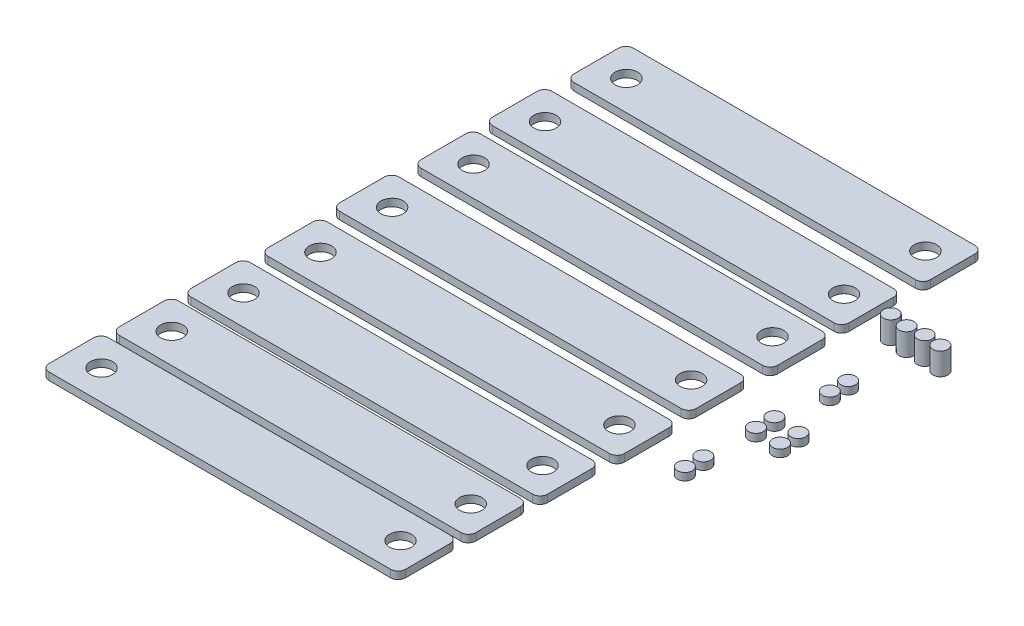
from build123d import *

# Parameters (mm, degrees)
SKETCH3_R              = 5
BOSS_EXTRUDE2_DEPTH    = 5
BOSS_EXTRUDE2_2_DEPTH  = 5
BOSS_EXTRUDE2_3_DEPTH  = 5
BOSS_EXTRUDE2_4_DEPTH  = 5
BOSS_EXTRUDE2_5_DEPTH  = 5
BOSS_EXTRUDE2_6_DEPTH  = 5
BOSS_EXTRUDE2_7_DEPTH  = 5
BOSS_EXTRUDE2_8_DEPTH  = 5
SKETCH3_R_2            = 7.5
BOSS_EXTRUDE2_9_DEPTH  = 5
BOSS_EXTRUDE2_10_DEPTH = 5
BOSS_EXTRUDE2_11_DEPTH = 5
BOSS_EXTRUDE2_12_DEPTH = 5
BOSS_EXTRUDE2_13_DEPTH = 5
BOSS_EXTRUDE2_14_DEPTH = 5
BOSS_EXTRUDE2_15_DEPTH = 5
BOSS_EXTRUDE2_16_DEPTH = 5
SKETCH9_R              = 5
BOSS_EXTRUDE3_DEPTH    = 15
BOSS_EXTRUDE3_2_DEPTH  = 15
BOSS_EXTRUDE3_3_DEPTH  = 15
BOSS_EXTRUDE3_4_DEPTH  = 15


with BuildPart() as part:
    # Sketch3 → Boss-Extrude2 (new body)
    with BuildSketch(Plane(origin=(0, 0, 0), x_dir=(1, 0, 0), z_dir=(0, 1, 0))):
        with Locations((149.537044307, 9.749777699)):
            Circle(SKETCH3_R)
    extrude(amount=BOSS_EXTRUDE2_DEPTH)


with BuildPart() as body_2:
    # Sketch3 → Boss-Extrude2 2 (new body)
    with BuildSketch(Plane(origin=(0, 0, 0), x_dir=(1, 0, 0), z_dir=(0, 1, 0))):
        with Locations((149.537044307, -2.604675007)):
            Circle(SKETCH3_R)
    extrude(amount=BOSS_EXTRUDE2_2_DEPTH)


with BuildPart() as body_3:
    # Sketch3 → Boss-Extrude2 3 (new body)
    with BuildSketch(Plane(origin=(0, 0, 0), x_dir=(1, 0, 0), z_dir=(0, 1, 0))):
        with Locations((145.856610502, -36.255644862)):
            Circle(SKETCH3_R)
    extrude(amount=BOSS_EXTRUDE2_3_DEPTH)


with BuildPart() as body_4:
    # Sketch3 → Boss-Extrude2 4 (new body)
    with BuildSketch(Plane(origin=(0, 0, 0), x_dir=(1, 0, 0), z_dir=(0, 1, 0))):
        with Locations((145.856610502, -48.610097567)):
            Circle(SKETCH3_R)
    extrude(amount=BOSS_EXTRUDE2_4_DEPTH)


with BuildPart() as body_5:
    # Sketch3 → Boss-Extrude2 5 (new body)
    with BuildSketch(Plane(origin=(0, 0, 0), x_dir=(1, 0, 0), z_dir=(0, 1, 0))):
        with Locations((144.75248036, -82.997154184)):
            Circle(SKETCH3_R)
    extrude(amount=BOSS_EXTRUDE2_5_DEPTH)


with BuildPart() as body_6:
    # Sketch3 → Boss-Extrude2 6 (new body)
    with BuildSketch(Plane(origin=(0, 0, 0), x_dir=(1, 0, 0), z_dir=(0, 1, 0))):
        with Locations((144.75248036, -95.351606889)):
            Circle(SKETCH3_R)
    extrude(amount=BOSS_EXTRUDE2_6_DEPTH)


with BuildPart() as body_7:
    # Sketch3 → Boss-Extrude2 7 (new body)
    with BuildSketch(Plane(origin=(0, 0, 0), x_dir=(1, 0, 0), z_dir=(0, 1, 0))):
        with Locations((163.154649385, -37.359775004)):
            Circle(SKETCH3_R)
    extrude(amount=BOSS_EXTRUDE2_7_DEPTH)


with BuildPart() as body_8:
    # Sketch3 → Boss-Extrude2 8 (new body)
    with BuildSketch(Plane(origin=(0, 0, 0), x_dir=(1, 0, 0), z_dir=(0, 1, 0))):
        with Locations((163.154649385, -49.714227709)):
            Circle(SKETCH3_R)
    extrude(amount=BOSS_EXTRUDE2_8_DEPTH)


with BuildPart() as body_9:
    # Sketch3 → Boss-Extrude2 9 (new body)
    with BuildSketch(Plane(origin=(0, 0, 0), x_dir=(1, 0, 0), z_dir=(0, 1, 0))):
        with BuildLine():
            Line((-120.270545649, -22.829813293), (109.729454351, -22.829813293))
            ThreePointArc((109.729454351, -22.829813293), (113.264988257, -24.294279387), (114.729454351, -27.829813293))
            Line((114.729454351, -27.829813293), (114.729454351, -57.829813293))
            ThreePointArc((114.729454351, -57.829813293), (113.264988257, -61.365347199), (109.729454351, -62.829813293))
            Line((109.729454351, -62.829813293), (-120.270545649, -62.829813293))
            ThreePointArc((-120.270545649, -62.829813293), (-123.806079555, -61.365347199), (-125.270545649, -57.829813293))
            Line((-125.270545649, -57.829813293), (-125.270545649, -27.829813293))
            ThreePointArc((-125.270545649, -27.829813293), (-123.806079555, -24.294279387), (-120.270545649, -22.829813293))
        make_face()
        with Locations((-104.955380734, -42.829813293)):
            Circle(SKETCH3_R_2, mode=Mode.SUBTRACT)
        with Locations((96.367895313, -42.829813293)):
            Circle(SKETCH3_R_2, mode=Mode.SUBTRACT)
    extrude(amount=BOSS_EXTRUDE2_9_DEPTH)


with BuildPart() as body_10:
    # Sketch3 → Boss-Extrude2 10 (new body)
    with BuildSketch(Plane(origin=(0, 0, 0), x_dir=(1, 0, 0), z_dir=(0, 1, 0))):
        with BuildLine():
            Line((-118.048872791, 29.749777699), (111.951127209, 29.749777699))
            ThreePointArc((111.951127209, 29.749777699), (115.486661115, 28.285311605), (116.951127209, 24.749777699))
            Line((116.951127209, 24.749777699), (116.951127209, -5.250222301))
            ThreePointArc((116.951127209, -5.250222301), (115.486661115, -8.785756207), (111.951127209, -10.250222301))
            Line((111.951127209, -10.250222301), (-118.048872791, -10.250222301))
            ThreePointArc((-118.048872791, -10.250222301), (-121.584406697, -8.785756207), (-123.048872791, -5.250222301))
            Line((-123.048872791, -5.250222301), (-123.048872791, 24.749777699))
            ThreePointArc((-123.048872791, 24.749777699), (-121.584406697, 28.285311605), (-118.048872791, 29.749777699))
        make_face()
        with Locations((-102.733707875, 9.749777699)):
            Circle(SKETCH3_R_2, mode=Mode.SUBTRACT)
        with Locations((98.589568172, 9.749777699)):
            Circle(SKETCH3_R_2, mode=Mode.SUBTRACT)
    extrude(amount=BOSS_EXTRUDE2_10_DEPTH)


with BuildPart() as body_11:
    # Sketch3 → Boss-Extrude2 11 (new body)
    with BuildSketch(Plane(origin=(0, 0, 0), x_dir=(1, 0, 0), z_dir=(0, 1, 0))):
        with BuildLine():
            Line((-120.365844272, -122.797427213), (109.634155728, -122.797427213))
            ThreePointArc((109.634155728, -122.797427213), (113.169689634, -124.261893307), (114.634155728, -127.797427213))
            Line((114.634155728, -127.797427213), (114.634155728, -157.797427213))
            ThreePointArc((114.634155728, -157.797427213), (113.169689634, -161.332961119), (109.634155728, -162.797427213))
            Line((109.634155728, -162.797427213), (-120.365844272, -162.797427213))
            ThreePointArc((-120.365844272, -162.797427213), (-123.901378178, -161.332961119), (-125.365844272, -157.797427213))
            Line((-125.365844272, -157.797427213), (-125.365844272, -127.797427213))
            ThreePointArc((-125.365844272, -127.797427213), (-123.901378178, -124.261893307), (-120.365844272, -122.797427213))
        make_face()
        with Locations((-105.050679357, -142.797427213)):
            Circle(SKETCH3_R_2, mode=Mode.SUBTRACT)
        with Locations((96.27259669, -142.797427213)):
            Circle(SKETCH3_R_2, mode=Mode.SUBTRACT)
    extrude(amount=BOSS_EXTRUDE2_11_DEPTH)


with BuildPart() as body_12:
    # Sketch3 → Boss-Extrude2 12 (new body)
    with BuildSketch(Plane(origin=(0, 0, 0), x_dir=(1, 0, 0), z_dir=(0, 1, 0))):
        with BuildLine():
            Line((-118.17072499, -73.187731426), (111.82927501, -73.187731426))
            ThreePointArc((111.82927501, -73.187731426), (115.364808916, -74.65219752), (116.82927501, -78.187731426))
            Line((116.82927501, -78.187731426), (116.82927501, -108.187731426))
            ThreePointArc((116.82927501, -108.187731426), (115.364808916, -111.723265332), (111.82927501, -113.187731426))
            Line((111.82927501, -113.187731426), (-118.17072499, -113.187731426))
            ThreePointArc((-118.17072499, -113.187731426), (-121.706258896, -111.723265332), (-123.17072499, -108.187731426))
            Line((-123.17072499, -108.187731426), (-123.17072499, -78.187731426))
            ThreePointArc((-123.17072499, -78.187731426), (-121.706258896, -74.65219752), (-118.17072499, -73.187731426))
        make_face()
        with Locations((-102.855560074, -93.187731426)):
            Circle(SKETCH3_R_2, mode=Mode.SUBTRACT)
        with Locations((98.467715973, -93.187731426)):
            Circle(SKETCH3_R_2, mode=Mode.SUBTRACT)
    extrude(amount=BOSS_EXTRUDE2_12_DEPTH)


with BuildPart() as body_13:
    # Sketch3 → Boss-Extrude2 13 (new body)
    with BuildSketch(Plane(origin=(0, 0, 0), x_dir=(1, 0, 0), z_dir=(0, 1, 0))):
        with BuildLine():
            Line((-122.121939698, -169.333956004), (107.878060302, -169.333956004))
            ThreePointArc((107.878060302, -169.333956004), (111.413594208, -170.798422098), (112.878060302, -174.333956004))
            Line((112.878060302, -174.333956004), (112.878060302, -204.333956004))
            ThreePointArc((112.878060302, -204.333956004), (111.413594208, -207.86948991), (107.878060302, -209.333956004))
            Line((107.878060302, -209.333956004), (-122.121939698, -209.333956004))
            ThreePointArc((-122.121939698, -209.333956004), (-125.657473604, -207.86948991), (-127.121939698, -204.333956004))
            Line((-127.121939698, -204.333956004), (-127.121939698, -174.333956004))
            ThreePointArc((-127.121939698, -174.333956004), (-125.657473604, -170.798422098), (-122.121939698, -169.333956004))
        make_face()
        with Locations((-106.806774783, -189.333956004)):
            Circle(SKETCH3_R_2, mode=Mode.SUBTRACT)
        with Locations((94.516501264, -189.333956004)):
            Circle(SKETCH3_R_2, mode=Mode.SUBTRACT)
    extrude(amount=BOSS_EXTRUDE2_13_DEPTH)


with BuildPart() as body_14:
    # Sketch3 → Boss-Extrude2 14 (new body)
    with BuildSketch(Plane(origin=(0, 0, 0), x_dir=(1, 0, 0), z_dir=(0, 1, 0))):
        with BuildLine():
            Line((-118.756382516, 78.619116624), (111.243617484, 78.619116624))
            ThreePointArc((111.243617484, 78.619116624), (114.77915139, 77.15465053), (116.243617484, 73.619116624))
            Line((116.243617484, 73.619116624), (116.243617484, 43.619116624))
            ThreePointArc((116.243617484, 43.619116624), (114.77915139, 40.083582718), (111.243617484, 38.619116624))
            Line((111.243617484, 38.619116624), (-118.756382516, 38.619116624))
            ThreePointArc((-118.756382516, 38.619116624), (-122.291916422, 40.083582718), (-123.756382516, 43.619116624))
            Line((-123.756382516, 43.619116624), (-123.756382516, 73.619116624))
            ThreePointArc((-123.756382516, 73.619116624), (-122.291916422, 77.15465053), (-118.756382516, 78.619116624))
        make_face()
        with Locations((-103.441217601, 58.619116624)):
            Circle(SKETCH3_R_2, mode=Mode.SUBTRACT)
        with Locations((97.882058446, 58.619116624)):
            Circle(SKETCH3_R_2, mode=Mode.SUBTRACT)
    extrude(amount=BOSS_EXTRUDE2_14_DEPTH)


with BuildPart() as body_15:
    # Sketch3 → Boss-Extrude2 15 (new body)
    with BuildSketch(Plane(origin=(0, 0, 0), x_dir=(1, 0, 0), z_dir=(0, 1, 0))):
        with BuildLine():
            Line((-116.534709657, 131.198707616), (113.465290343, 131.198707616))
            ThreePointArc((113.465290343, 131.198707616), (117.000824248, 129.734241522), (118.465290343, 126.198707616))
            Line((118.465290343, 126.198707616), (118.465290343, 96.198707616))
            ThreePointArc((118.465290343, 96.198707616), (117.000824248, 92.66317371), (113.465290343, 91.198707616))
            Line((113.465290343, 91.198707616), (-116.534709657, 91.198707616))
            ThreePointArc((-116.534709657, 91.198707616), (-120.070243563, 92.66317371), (-121.534709657, 96.198707616))
            Line((-121.534709657, 96.198707616), (-121.534709657, 126.198707616))
            ThreePointArc((-121.534709657, 126.198707616), (-120.070243563, 129.734241522), (-116.534709657, 131.198707616))
        make_face()
        with Locations((-101.219544742, 111.198707616)):
            Circle(SKETCH3_R_2, mode=Mode.SUBTRACT)
        with Locations((100.103731305, 111.198707616)):
            Circle(SKETCH3_R_2, mode=Mode.SUBTRACT)
    extrude(amount=BOSS_EXTRUDE2_15_DEPTH)


with BuildPart() as body_16:
    # Sketch3 → Boss-Extrude2 16 (new body)
    with BuildSketch(Plane(origin=(0, 0, 0), x_dir=(1, 0, 0), z_dir=(0, 1, 0))):
        with BuildLine():
            Line((-124.37505078, -214.396177643), (105.62494922, -214.396177643))
            ThreePointArc((105.62494922, -214.396177643), (109.160483126, -215.860643737), (110.62494922, -219.396177643))
            Line((110.62494922, -219.396177643), (110.62494922, -249.396177643))
            ThreePointArc((110.62494922, -249.396177643), (109.160483126, -252.931711549), (105.62494922, -254.396177643))
            Line((105.62494922, -254.396177643), (-124.37505078, -254.396177643))
            ThreePointArc((-124.37505078, -254.396177643), (-127.910584686, -252.931711549), (-129.37505078, -249.396177643))
            Line((-129.37505078, -249.396177643), (-129.37505078, -219.396177643))
            ThreePointArc((-129.37505078, -219.396177643), (-127.910584686, -215.860643737), (-124.37505078, -214.396177643))
        make_face()
        with Locations((-109.059885865, -234.396177643)):
            Circle(SKETCH3_R_2, mode=Mode.SUBTRACT)
        with Locations((92.263390182, -234.396177643)):
            Circle(SKETCH3_R_2, mode=Mode.SUBTRACT)
    extrude(amount=BOSS_EXTRUDE2_16_DEPTH)


with BuildPart() as body_17:
    # Sketch9 → Boss-Extrude3 (new body)
    with BuildSketch(Plane(origin=(0, 5, 0), x_dir=(1, 0, 0), z_dir=(0, 1, 0))):
        with Locations((140.045507905, 47.930405311)):
            Circle(SKETCH9_R)
    extrude(amount=BOSS_EXTRUDE3_DEPTH)


with BuildPart() as body_18:
    # Sketch9 → Boss-Extrude3 2 (new body)
    with BuildSketch(Plane(origin=(0, 5, 0), x_dir=(1, 0, 0), z_dir=(0, 1, 0))):
        with Locations((152.348623344, 46.31625897)):
            Circle(SKETCH9_R)
    extrude(amount=BOSS_EXTRUDE3_2_DEPTH)


with BuildPart() as body_19:
    # Sketch9 → Boss-Extrude3 3 (new body)
    with BuildSketch(Plane(origin=(0, 5, 0), x_dir=(1, 0, 0), z_dir=(0, 1, 0))):
        with Locations((163.646545465, 47.217713617)):
            Circle(SKETCH9_R)
    extrude(amount=BOSS_EXTRUDE3_3_DEPTH)


with BuildPart() as body_20:
    # Sketch9 → Boss-Extrude3 4 (new body)
    with BuildSketch(Plane(origin=(0, 5, 0), x_dir=(1, 0, 0), z_dir=(0, 1, 0))):
        with Locations((174.986162006, 46.423422818)):
            Circle(SKETCH9_R)
    extrude(amount=BOSS_EXTRUDE3_4_DEPTH)


solid = Compound([part.part, body_2.part, body_3.part, body_4.part, body_5.part, body_6.part, body_7.part, body_8.part, body_9.part, body_10.part, body_11.part, body_12.part, body_13.part, body_14.part, body_15.part, body_16.part, body_17.part, body_18.part, body_19.part, body_20.part])
